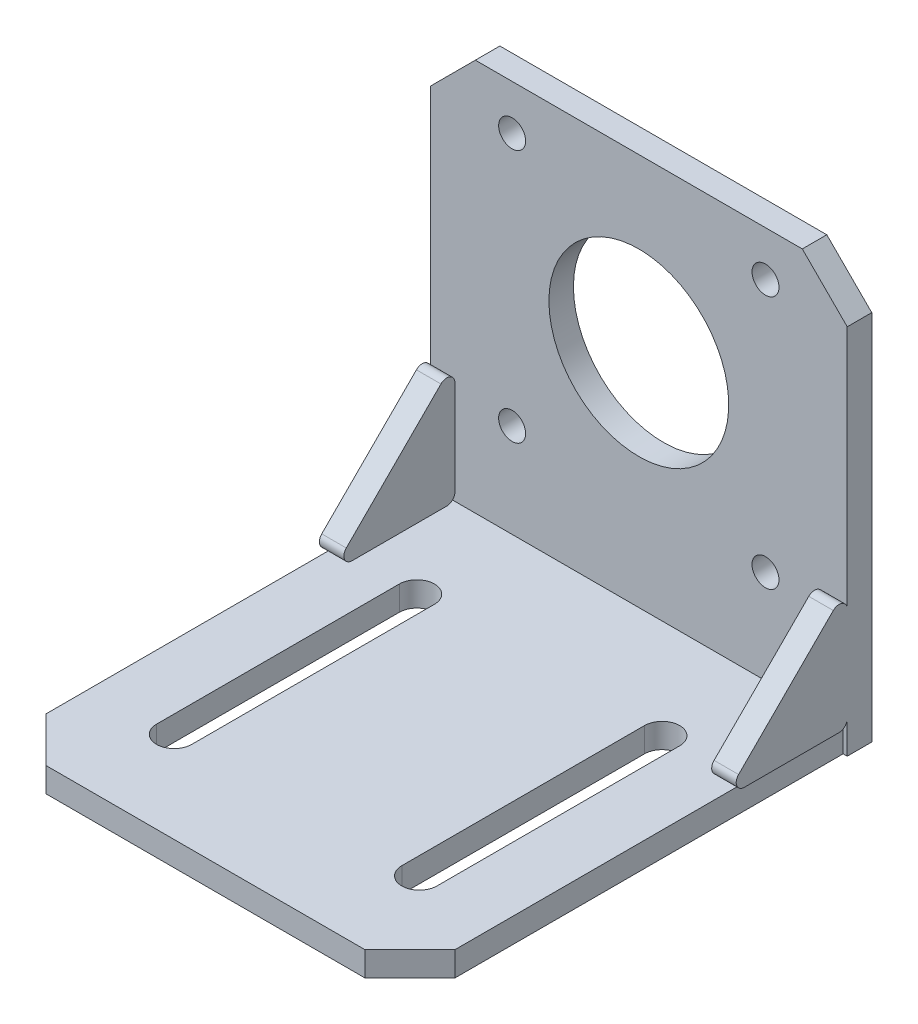
from build123d import *

# Parameters (mm, degrees)
EXTRUDE_1_DEPTH = 3
SKETCH_2_R      = 11
SKETCH_2_R_2    = 1.65
EXTRUDE_2_DEPTH = 3
EXTRUDE_3_DEPTH = 3


with BuildPart() as part:
    # 草图1 → 凸台-拉伸1 (new body)
    with BuildSketch(Plane(origin=(0, 0, 0), x_dir=(1, 0, 0), z_dir=(0, 1, 0))):
        Polygon((19.5, -53), (25, -47.5), (25, 0), (-25, 0), (-25, -47.5), (-19.5, -53), align=None)
        with BuildLine():
            Line((17.15, -12.15), (17.15, -41.85))
            ThreePointArc((17.15, -41.85), (15, -44), (12.85, -41.85))
            Line((12.85, -41.85), (12.85, -12.15))
            ThreePointArc((12.85, -12.15), (15, -10), (17.15, -12.15))
        make_face(mode=Mode.SUBTRACT)
        with BuildLine():
            Line((-17.15, -12.15), (-17.15, -41.85))
            ThreePointArc((-17.15, -41.85), (-15, -44), (-12.85, -41.85))
            Line((-12.85, -41.85), (-12.85, -12.15))
            ThreePointArc((-12.85, -12.15), (-15, -10), (-17.15, -12.15))
        make_face(mode=Mode.SUBTRACT)
    extrude(amount=-EXTRUDE_1_DEPTH)

    # 草图2 → 凸台-拉伸2 (add)
    with BuildSketch(Plane(origin=(0, 0, 0), x_dir=(-1, 0, 0), z_dir=(0, 0, -1))):
        Polygon((-25.5, -3), (25.5, -3), (25.5, 42.5), (20, 48), (-20, 48), (-25.5, 42.5), align=None)
        with Locations((0, 27)):
            Circle(SKETCH_2_R, mode=Mode.SUBTRACT)
        with Locations((-15.5, 42.5)):
            Circle(SKETCH_2_R_2, mode=Mode.SUBTRACT)
        with Locations((-15.5, 11.5)):
            Circle(SKETCH_2_R_2, mode=Mode.SUBTRACT)
        with Locations((15.5, 11.5)):
            Circle(SKETCH_2_R_2, mode=Mode.SUBTRACT)
        with Locations((15.5, 42.5)):
            Circle(SKETCH_2_R_2, mode=Mode.SUBTRACT)
    extrude(amount=EXTRUDE_2_DEPTH)

    # 草图4 → 凸台-拉伸3 (add)
    with BuildSketch(Plane(origin=(25.5, 0, 0), x_dir=(0, 0, -1), z_dir=(1, 0, 0))):
        with BuildLine():
            Line((-1.707106781, 13.292893219), (-13.292893219, 1.707106781))
            ThreePointArc((-13.292893219, 1.707106781), (-13.50966597, 0.617316568), (-12.585786438, 0))
            Line((-12.585786438, 0), (-1, 0))
            ThreePointArc((-1, 0), (-0.292893219, 0.292893219), (0, 1))
            Line((0, 1), (0, 12.585786438))
            ThreePointArc((0, 12.585786438), (-0.617316568, 13.50966597), (-1.707106781, 13.292893219))
        make_face()
    extrude_3 = extrude(amount=-EXTRUDE_3_DEPTH)

    # 镜向1: 凸台-拉伸3 across plane
    add(extrude_3.mirror(Plane(origin=(0, 0, 0), x_dir=(0, 0, 1), z_dir=(1, 0, 0))))


solid = part.part
